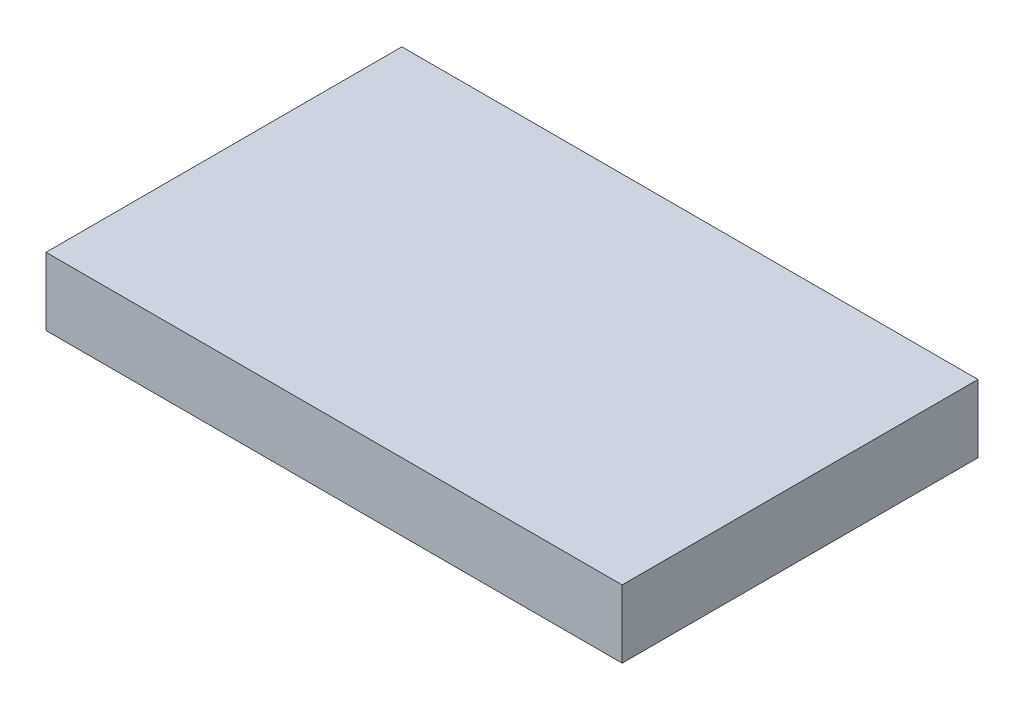
from build123d import *

# Parameters (mm, degrees)
SKETCH1_W           = 17
SKETCH1_H           = 10.5
BOSS_EXTRUDE1_DEPTH = 2


with BuildPart() as part:
    # Sketch1 → Boss-Extrude1 (new body)
    with BuildSketch(Plane(origin=(0, 0, 0), x_dir=(1, 0, 0), z_dir=(0, 1, 0))):
        Rectangle(SKETCH1_W, SKETCH1_H)
    extrude(amount=BOSS_EXTRUDE1_DEPTH)


solid = part.part
